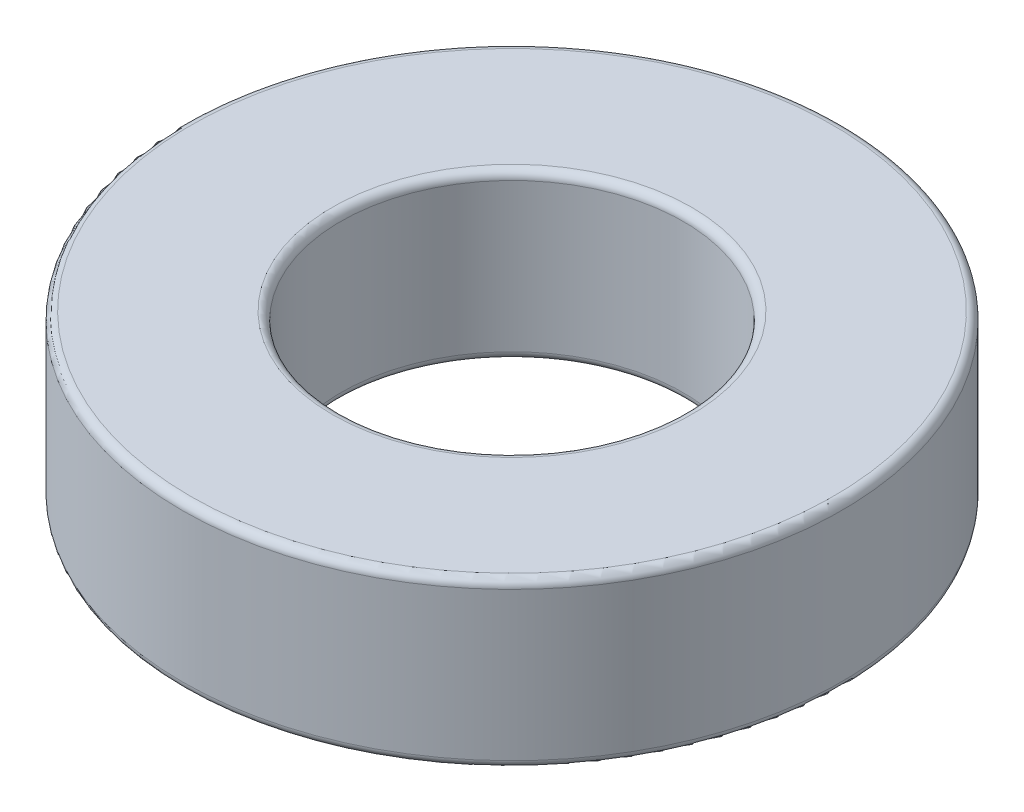
from build123d import *

# Parameters (mm, degrees)
SKETCH2_R    = 6.35
SKETCH2_R_2  = 3.302
SPACER_DEPTH = 3.175
FILLET_2_R   = 0.15875


with BuildPart() as part:
    # Sketch2 → Spacer (new body)
    with BuildSketch(Plane(origin=(0, 0, 0), x_dir=(1, 0, 0), z_dir=(0, 1, 0))):
        Circle(SKETCH2_R)
        Circle(SKETCH2_R_2, mode=Mode.SUBTRACT)
    extrude(amount=SPACER_DEPTH)

    # Fillet 2
    fillet_2_edges = [part.edges().sort_by_distance(p)[0] for p in [
        (-6.35, 0, 0),
        (-6.35, 3.175, 0),
        (-3.302, 0, 0),
        (-3.302, 3.175, 0),
    ]]
    fillet(fillet_2_edges, radius=FILLET_2_R)


solid = part.part
